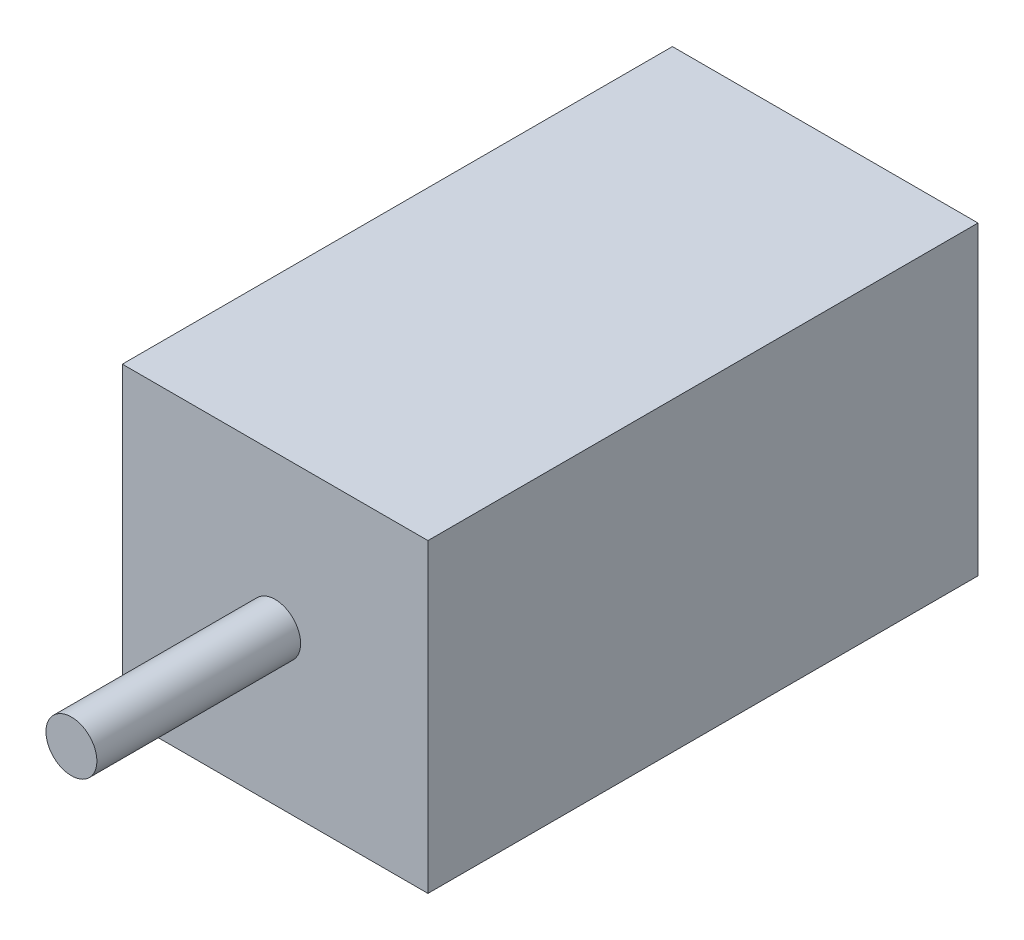
from build123d import *

# Parameters (mm, degrees)
SKETCH1_W           = 15
SKETCH1_H           = 15
BOSS_EXTRUDE1_DEPTH = 27
SKETCH2_R           = 1.25
BOSS_EXTRUDE2_DEPTH = 10


with BuildPart() as part:
    # Sketch1 → Boss-Extrude1 (new body)
    with BuildSketch(Plane.XY):
        with Locations((7.5, -7.5)):
            Rectangle(SKETCH1_W, SKETCH1_H)
    extrude(amount=BOSS_EXTRUDE1_DEPTH)

    # Sketch2 → Boss-Extrude2 (add)
    with BuildSketch(Plane.XY.offset(27)):
        with Locations((7.5, -7.5)):
            Circle(SKETCH2_R)
    extrude(amount=BOSS_EXTRUDE2_DEPTH)


solid = part.part
